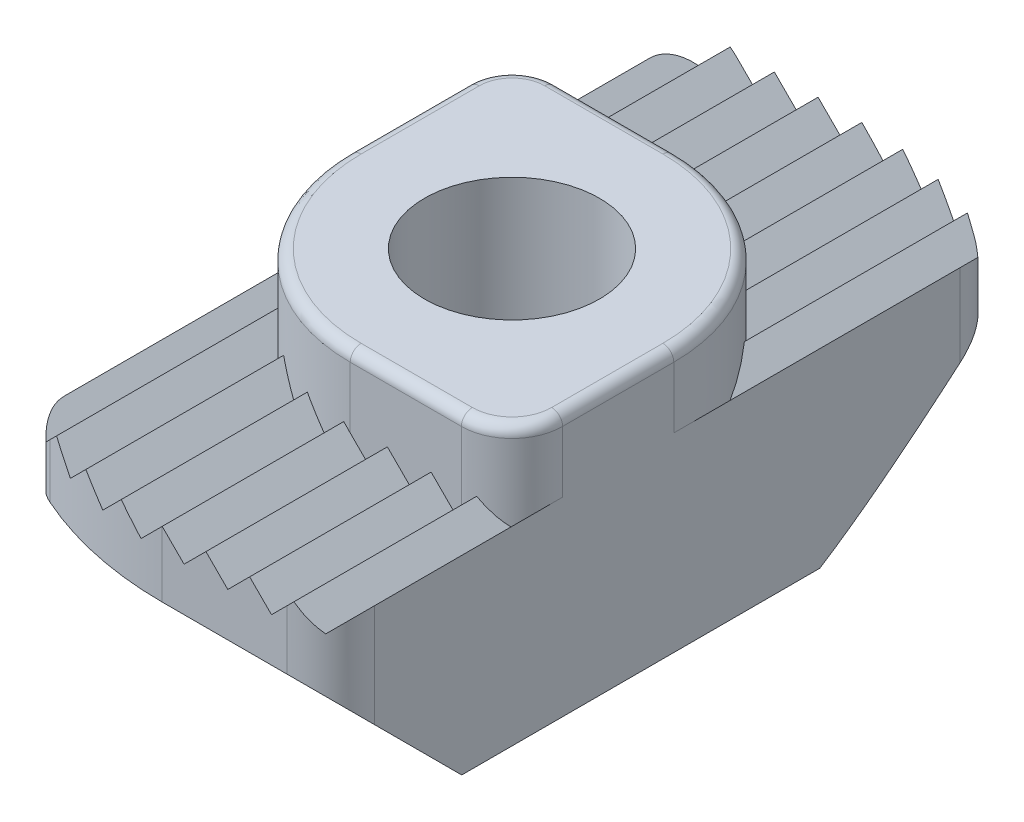
from build123d import *

# Parameters (mm, degrees)
EXTRUDE1_DEPTH          = 4.5
CUT_EXTRUDE1_DEPTH      = 8
CUT_EXTRUDE1_DEPTH_BACK = 8
EXTRUDE2_DEPTH          = 6.00039994
CUT_EXTRUDE2_DEPTH      = 4
CUT_EXTRUDE2_DEPTH_BACK = 4
CUT_REVOLVE1_ANGLE      = 60
CUT_REVOLVE2_ANGLE      = 60
SKETCH9_R               = 2.48793
CUT_EXTRUDE3_DEPTH      = 7.00040004
FILLET4_R               = 0.25
SKETCH10_R              = 2.48793
EXTRUDE3_DEPTH          = 6.0004
SKETCH12_R              = 2
CUT_EXTRUDE4_DEPTH      = 7.00040004


with BuildPart() as part:
    # Sketch1 → Extrude1 (new body)
    with BuildSketch(Plane(origin=(0, 0, 0), x_dir=(1, 0, 0), z_dir=(0, 1, 0))):
        with BuildLine():
            Line((0, -8), (2.85, -8))
            ThreePointArc((2.85, -8), (3.557106781, -7.707106781), (3.85, -7))
            Line((3.85, -7), (3.85, 6.393551439))
            ThreePointArc((3.85, 6.393551439), (3.688791661, 6.938003962), (3.2571429, 7.306915911))
            ThreePointArc((3.2571429, 7.306915911), (1.66503344, 7.824810774), (0, 8))
            Line((0, 8), (-2.85, 8))
            ThreePointArc((-2.85, 8), (-3.557106781, 7.707106781), (-3.85, 7))
            Line((-3.85, 7), (-3.85, -6.393551439))
            ThreePointArc((-3.85, -6.393551439), (-3.688791661, -6.938003962), (-3.2571429, -7.306915911))
            ThreePointArc((-3.2571429, -7.306915911), (-1.66503344, -7.824810774), (0, -8))
        make_face()
    extrude(amount=EXTRUDE1_DEPTH)

    # Sketch2 → Cut-Extrude1 (cut, two sides)
    with BuildSketch(Plane.XY) as cut_extrude1_sk:
        Polygon((-4, 4.5), (-3.5, 4), (-3, 4.5), (-2.5, 4), (-2, 4.5), (-1.5, 4), (-1, 4.5), (-0.5, 4), (0, 4.5), (0.5, 4), (1, 4.5), (1.5, 4), (2, 4.5), (2.5, 4), (3, 4.5), (3.5, 4), (4, 4.5), (4, 5.5), (-4, 5.5), align=None)
    extrude(amount=CUT_EXTRUDE1_DEPTH, mode=Mode.SUBTRACT)
    extrude(cut_extrude1_sk.sketch, amount=-CUT_EXTRUDE1_DEPTH_BACK, mode=Mode.SUBTRACT)

    # Sketch3 → Extrude2 (add)
    with BuildSketch(Plane(origin=(0, 0, 0), x_dir=(1, 0, 0), z_dir=(0, 1, 0))):
        with BuildLine():
            Line((0.15, -3.85), (2.693303618, -3.85))
            ThreePointArc((2.693303618, -3.85), (3.511211473, -3.511211473), (3.85, -2.693303618))
            Line((3.85, -2.693303618), (3.85, -0.15))
            ThreePointArc((3.85, -0.15), (2.678427125, 2.678427125), (-0.15, 3.85))
            Line((-0.15, 3.85), (-2.85, 3.85))
            ThreePointArc((-2.85, 3.85), (-3.557106781, 3.557106781), (-3.85, 2.85))
            Line((-3.85, 2.85), (-3.85, 0.15))
            ThreePointArc((-3.85, 0.15), (-2.678427125, -2.678427125), (0.15, -3.85))
        make_face()
    extrude(amount=EXTRUDE2_DEPTH)

    # Sketch4 → Cut-Extrude2 (cut, two sides)
    with BuildSketch(Plane(origin=(0, 0, 0), x_dir=(0, 0, -1), z_dir=(1, 0, 0))) as cut_extrude2_sk:
        Polygon((-9, -1), (9, -1), (9, 4), (5, 0), (-5, 0), (-9, 4), align=None)
    extrude(amount=CUT_EXTRUDE2_DEPTH, mode=Mode.SUBTRACT)
    extrude(cut_extrude2_sk.sketch, amount=-CUT_EXTRUDE2_DEPTH_BACK, mode=Mode.SUBTRACT)

    # Sketch5 → Cut-Revolve1 (revolve, cut)
    with BuildSketch(Plane(origin=(0, 0, 0), x_dir=(0, 0, -1), z_dir=(1, 0, 0))):
        Polygon((0, -1), (-9, -1), (-9, 3), (-8, 3), (-5, 0), (0, 0), align=None)
    revolve(axis=Axis((0, 3, 0), (0, -1, 0)), revolution_arc=CUT_REVOLVE1_ANGLE, mode=Mode.SUBTRACT)

    # Sketch6 → Cut-Revolve2 (revolve, cut)
    with BuildSketch(Plane(origin=(0, 0, 0), x_dir=(0, 0, -1), z_dir=(1, 0, 0))):
        Polygon((0, 0), (5, 0), (8, 3), (9, 3), (9, -1), (0, -1), align=None)
    revolve(axis=Axis((0, -1, 0), (0, -1, 0)), revolution_arc=CUT_REVOLVE2_ANGLE, mode=Mode.SUBTRACT)

    # Sketch9 → Cut-Extrude3 (cut, through all)
    with BuildSketch(Plane(origin=(0, 6.00039994, 0), x_dir=(1, 0, 0), z_dir=(0, 1, 0))):
        Circle(SKETCH9_R)
    extrude(amount=-CUT_EXTRUDE3_DEPTH, mode=Mode.SUBTRACT)

    # Fillet4
    fillet4_edges = [part.edges().sort_by_distance(p)[0] for p in [
        (-2.678427125, 6.00039994, 2.678427125),
        (1.421651809, 6.00039994, 3.85),
        (3.511211473, 6.00039994, 3.511211473),
        (3.85, 6.00039994, 1.421651809),
        (2.678427125, 6.00039994, -2.678427125),
        (-1.5, 6.00039994, -3.85),
        (-3.557106781, 6.00039994, -3.557106781),
        (-3.85, 6.00039994, -1.5),
    ]]
    fillet(fillet4_edges, radius=FILLET4_R)

    # Sketch10 → Extrude3 (add)
    with BuildSketch(Plane(origin=(0, 6.00039994, 0), x_dir=(1, 0, 0), z_dir=(0, 1, 0))):
        Circle(SKETCH10_R)
    extrude(amount=-EXTRUDE3_DEPTH)

    # Sketch12 → Cut-Extrude4 (cut, through all)
    with BuildSketch(Plane(origin=(0, 6.00039994, 0), x_dir=(1, 0, 0), z_dir=(0, 1, 0))):
        Circle(SKETCH12_R)
    extrude(amount=-CUT_EXTRUDE4_DEPTH, mode=Mode.SUBTRACT)


solid = part.part
